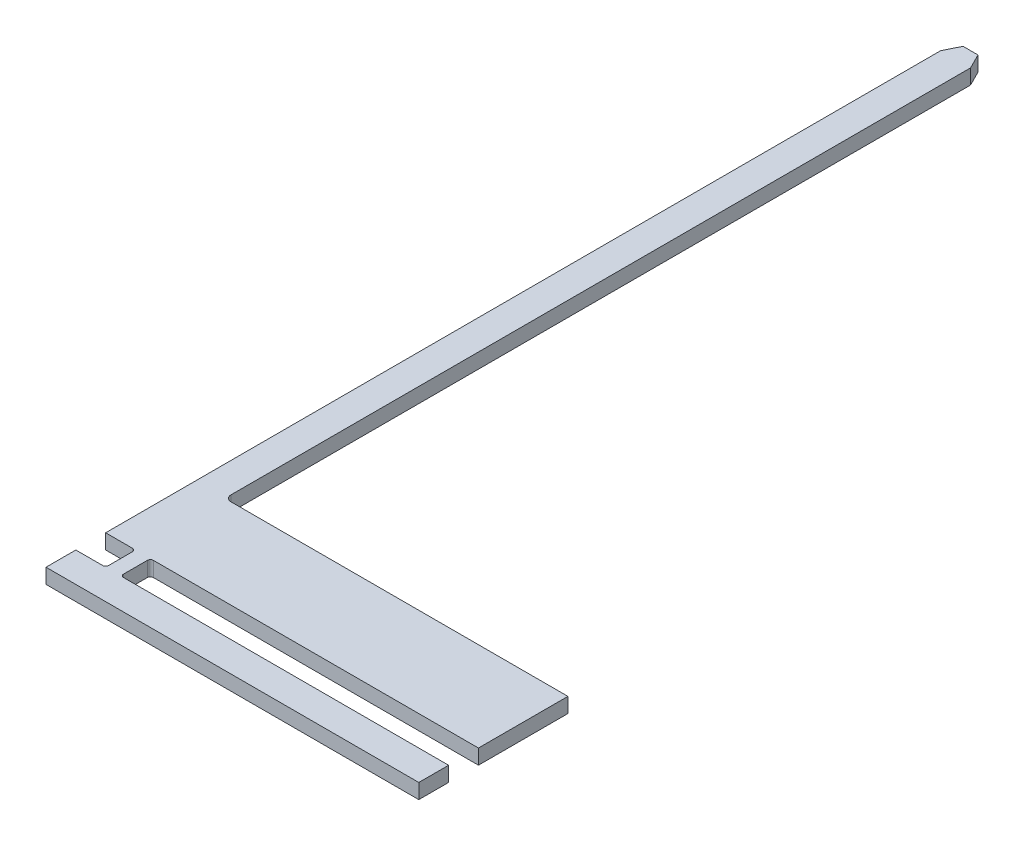
from build123d import *

# Parameters (mm, degrees)
BOSS_EXTRUDE1_DEPTH = 0.01


with BuildPart() as part:
    # Sketch1 → Boss-Extrude1 (new body)
    with BuildSketch(Plane(origin=(0, 0, 0), x_dir=(1, 0, 0), z_dir=(0, 1, 0))):
        with BuildLine():
            Line((-0.175207919, 0.454787097), (-0.180207919, 0.464787097))
            Line((-0.180207919, 0.464787097), (-0.190207919, 0.464787097))
            Line((-0.190207919, 0.464787097), (-0.195207919, 0.454787097))
            Line((-0.195207919, 0.454787097), (-0.195207919, -0.065212903))
            Line((-0.195207919, -0.065212903), (-0.195207919, -0.105212903))
            Line((-0.195207919, -0.105212903), (-0.177207919, -0.105212903))
            ThreePointArc((-0.177207919, -0.105212903), (-0.175793705, -0.10579869), (-0.175207919, -0.107212903))
            Line((-0.175207919, -0.107212903), (-0.175207919, -0.123212903))
            ThreePointArc((-0.175207919, -0.123212903), (-0.175793705, -0.124627117), (-0.177207919, -0.125212903))
            Line((-0.177207919, -0.125212903), (-0.195207919, -0.125212903))
            Line((-0.195207919, -0.125212903), (-0.195207919, -0.145212903))
            Line((-0.195207919, -0.145212903), (0.054792081, -0.145212903))
            Line((0.054792081, -0.145212903), (0.054792081, -0.125212903))
            Line((0.054792081, -0.125212903), (-0.163207919, -0.125212903))
            ThreePointArc((-0.163207919, -0.125212903), (-0.164622133, -0.124627117), (-0.165207919, -0.123212903))
            Line((-0.165207919, -0.123212903), (-0.165207919, -0.107212903))
            ThreePointArc((-0.165207919, -0.107212903), (-0.164622133, -0.10579869), (-0.163207919, -0.105212903))
            Line((-0.163207919, -0.105212903), (0.054792081, -0.105212903))
            Line((0.054792081, -0.105212903), (0.054792081, -0.045212903))
            Line((0.054792081, -0.045212903), (-0.171207919, -0.045212903))
            ThreePointArc((-0.171207919, -0.045212903), (-0.174036346, -0.04404133), (-0.175207919, -0.041212903))
            Line((-0.175207919, -0.041212903), (-0.175207919, 0.454787097))
        make_face()
    extrude(amount=BOSS_EXTRUDE1_DEPTH)


solid = part.part
